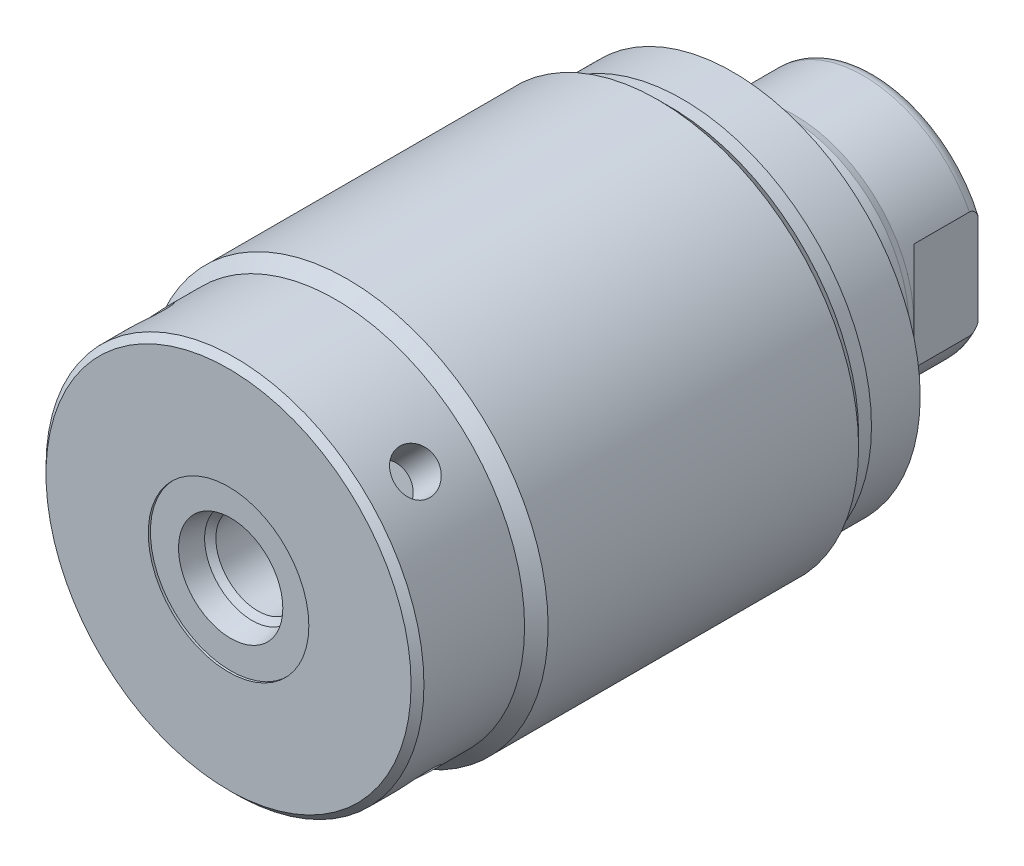
from build123d import *

# Parameters (mm, degrees)
SKETCH1_R          = 23.8125
EXTRUDE1_DEPTH     = 53.848
CHAMFER1_SIZE      = 0.762
SKETCH6_R          = 22.225
EXTRUDE2_DEPTH     = 5.969
SKETCH7_W          = 16.51
SKETCH7_H          = 14.2875
CUT_EXTRUDE4_DEPTH = 19.84248
HOLE1_D            = 5.0038
HOLE1_DEPTH        = 4.7498
CIRPATTERN1_COUNT  = 4


with BuildPart() as part:
    # Sketch1 → Extrude1 (new body)
    with BuildSketch(Plane.XY):
        Circle(SKETCH1_R)
    extrude(amount=EXTRUDE1_DEPTH)

    # Sketch2 → Cut-Revolve1 (revolve, cut)
    with BuildSketch(Plane(origin=(0, 0, 0), x_dir=(1, 0, 0), z_dir=(0, 1, 0)), mode=Mode.PRIVATE) as cut_revolve1_sk:
        Polygon((23.8125, -53.848), (23.8125, -39.751), (22.4155, -41.148), (22.4155, -53.848), align=None)
    revolve(cut_revolve1_sk.sketch.rotate(Axis((0, 0, 0), (0, 0, 1)), 180), axis=Axis((0, 0, 0), (0, 0, 1)), mode=Mode.SUBTRACT)  # turned: the seam where the file's is

    # Sketch3 → Cut-Revolve2 (revolve, cut)
    with BuildSketch(Plane(origin=(0, 0, 0), x_dir=(1, 0, 0), z_dir=(0, 1, 0)), mode=Mode.PRIVATE) as cut_revolve2_sk:
        Polygon((22.4155, 0), (22.4155, -1.524), (23.8125, -2.921), (23.8125, 0), align=None)
    revolve(cut_revolve2_sk.sketch.rotate(Axis((0, 0, 0), (0, 0, -1)), 180), axis=Axis((0, 0, 0), (0, 0, -1)), mode=Mode.SUBTRACT)  # turned: the seam where the file's is

    # S2D0002 → Cut-Revolve3 (revolve, cut)
    with BuildSketch(Plane(origin=(0, 0, 0), x_dir=(1, 0, 0), z_dir=(0, 1, 0))):
        Polygon((6.1849, -53.594), (9.525, -53.594), (9.525, -53.848), (0, -53.848), (0, -39.624), (4.9784, -39.624), (4.9784, -50.377393135), (5.642306865, -51.0413), align=None)
    revolve(axis=Axis((0, 0, 14.6685), (0, 0, -1)), mode=Mode.SUBTRACT)

    # Chamfer1
    chamfer1_edges = [part.edges().sort_by_distance(p)[0] for p in [
        (22.4155, 0, 53.848),
    ]]
    chamfer(chamfer1_edges, length=CHAMFER1_SIZE)

    # Sketch6 → Extrude2 (add)
    with BuildSketch(Plane(origin=(0, 0, 0), x_dir=(-1, 0, 0), z_dir=(0, 0, -1))):
        with Locations(Location((0, 0, 0), (0, 0, 180))):  # turned: the seam where the file's is
            Circle(SKETCH6_R)
    extrude(amount=EXTRUDE2_DEPTH)

    # Sketch7 → Revolve1 (revolve)
    with BuildSketch(Plane(origin=(0, 0, 0), x_dir=(0, 0, -1), z_dir=(1, 0, 0)), mode=Mode.PRIVATE) as revolve1_sk:
        with Locations((14.224, -7.14375)):
            Rectangle(SKETCH7_W, SKETCH7_H)
    revolve(revolve1_sk.sketch.rotate(Axis((0, 0, 0), (0, 0, -1)), 270), axis=Axis((0, 0, 0), (0, 0, -1)))  # turned: the seam where the file's is

    # S2D0001 → Cut-Revolve5 (revolve, cut)
    with BuildSketch(Plane(origin=(0, 0, 0), x_dir=(1, 0, 0), z_dir=(0, 1, 0))):
        Polygon((5.5499, 20.411277746), (5.5499, 3.8608), (0, 3.8608), (0, 22.479), (6.7437, 22.479), align=None)
    revolve(axis=Axis((0, 0, 31.308359971), (0, 0, -1)), mode=Mode.SUBTRACT)

    # Sketch9 → Cut-Revolve6 (revolve, cut)
    with BuildSketch(Plane(origin=(0, 0, 0), x_dir=(0, -1, 0), z_dir=(1, 0, 0)), mode=Mode.PRIVATE) as cut_revolve6_sk:
        with BuildLine():
            Line((-14.2875, 12.573), (-14.097, 13.335))
            Line((-14.097, 13.335), (-14.097, 21.463))
            ThreePointArc((-14.097, 21.463), (-13.996678675, 22.006796865), (-13.708922533, 22.479))
            Line((-13.708922533, 22.479), (-14.2875, 22.479))
            Line((-14.2875, 22.479), (-14.2875, 12.573))
        make_face()
    revolve(cut_revolve6_sk.sketch.rotate(Axis((0, 0, -12.65936), (0, 0, -1)), 90), axis=Axis((0, 0, -12.65936), (0, 0, -1)), mode=Mode.SUBTRACT)  # turned: the seam where the file's is

    # Sketch13 → Cut-Extrude4 (cut, symmetric)
    with BuildSketch(Plane(origin=(0, 0, 0), x_dir=(1, 0, 0), z_dir=(0, 1, 0))):
        Polygon((12.573, 22.479), (12.573, 14.9098), (14.2875, 13.1953), (14.2875, 22.479), align=None)
        Polygon((-12.573, 22.479), (-12.573, 14.9098), (-14.2875, 13.1953), (-14.2875, 22.479), align=None)
    extrude(amount=CUT_EXTRUDE4_DEPTH, both=True, mode=Mode.SUBTRACT)

    # Hole1
    with Locations(Plane(origin=(-15.850152054, 15.850152054, 47.498), x_dir=(0.707106781, 0.707106781, 0), z_dir=(-0.707106781, 0.707106781, 0))):
        with Locations((0, 0)):
            hole1 = Hole(HOLE1_D / 2, depth=HOLE1_DEPTH)

    # CirPattern1: Hole1 ×4 about axis
    cirpattern1_axis = Axis((0, 0, 0), (0, 0, 1))
    for i in range(1, CIRPATTERN1_COUNT):
        add(hole1.rotate(cirpattern1_axis, i * 360 / CIRPATTERN1_COUNT), mode=Mode.SUBTRACT)


solid = part.part
